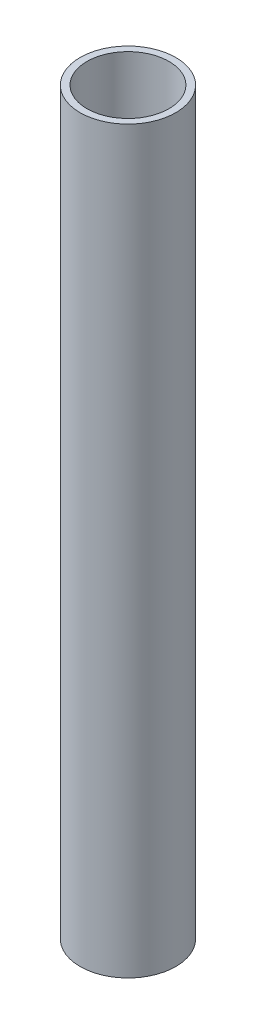
from build123d import *

# Parameters (mm, degrees)
SKETCH1_R           = 13.975
SKETCH1_R_2         = 11.975
BOSS_EXTRUDE1_DEPTH = 216


with BuildPart() as part:
    # Sketch1 → Boss-Extrude1 (new body)
    with BuildSketch(Plane(origin=(0, 0, 0), x_dir=(1, 0, 0), z_dir=(0, 1, 0))):
        Circle(SKETCH1_R)
        Circle(SKETCH1_R_2, mode=Mode.SUBTRACT)
    extrude(amount=BOSS_EXTRUDE1_DEPTH)


solid = part.part
